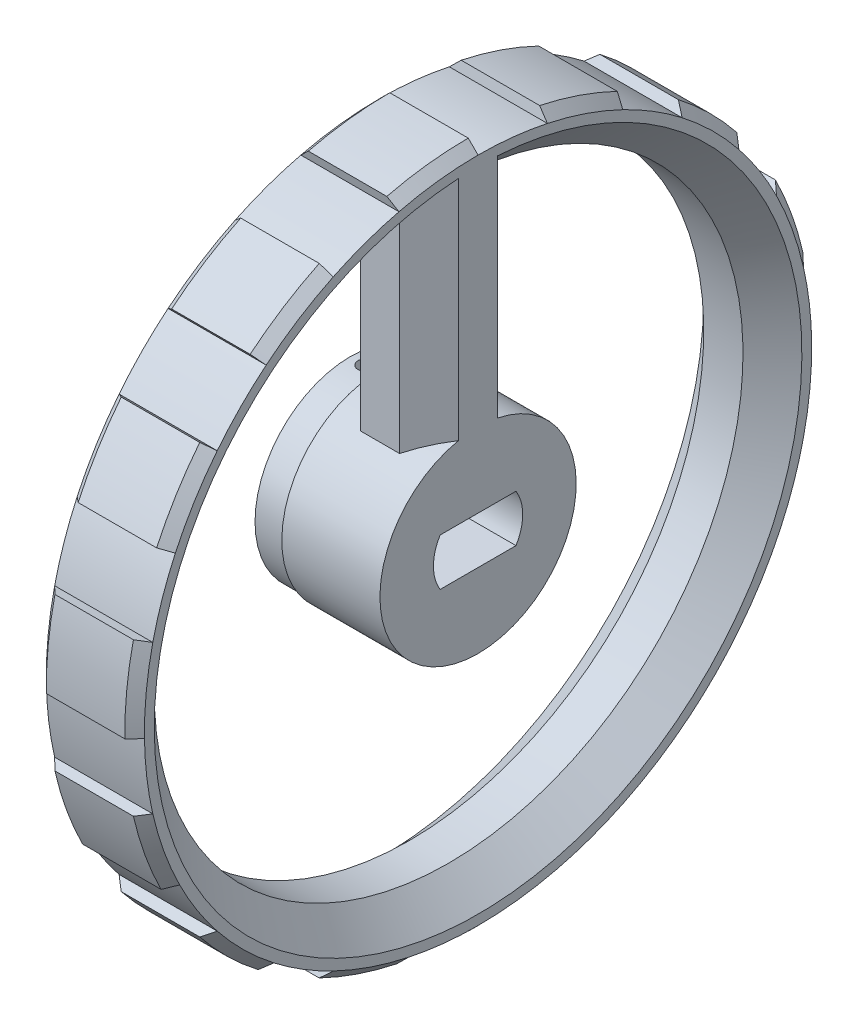
from build123d import *

# Parameters (mm, degrees)
SKETCH1_R               = 35
BOSS_EXTRUDE1_DEPTH     = 10
CHAMFER1_SIZE           = 1
CUT_EXTRUDE1_DEPTH      = 11
SKETCH3_R               = 1.5
CUT_EXTRUDE2_DEPTH      = 11
CUT_EXTRUDE3_DEPTH      = 10
SKETCH5_R               = 9.729015648
BOSS_EXTRUDE2_DEPTH     = 3
SKETCH6_R               = 0.75
CUT_EXTRUDE4_DEPTH      = 36
CUT_EXTRUDE4_DEPTH_BACK = 36
CHAMFER2_SIZE           = 3


with BuildPart() as part:
    # Sketch1 → Boss-Extrude1 (new body)
    with BuildSketch(Plane(origin=(0, 0, 0), x_dir=(0, 0, -1), z_dir=(1, 0, 0))):
        Circle(SKETCH1_R)
        with BuildLine():
            Line((-5, 29.580398915), (-5, 8.660254038))
            ThreePointArc((-5, 8.660254038), (0, -10), (5, 8.660254038))
            Line((5, 8.660254038), (5, 29.580398915))
            ThreePointArc((5, 29.580398915), (0, -30), (-5, 29.580398915))
        make_face(mode=Mode.SUBTRACT)
    extrude(amount=BOSS_EXTRUDE1_DEPTH)

    # Chamfer1
    chamfer1_edges = [part.edges().sort_by_distance(p)[0] for p in [
        (0, 0, 35),
        (10, 0, 35),
    ]]
    chamfer(chamfer1_edges, length=CHAMFER1_SIZE)

    # Sketch2 → Cut-Extrude1 (cut, through all)
    with BuildSketch(Plane(origin=(10, 0, 0), x_dir=(0, 0, -1), z_dir=(1, 0, 0))):
        with BuildLine():
            Line((0, 35), (0, 34))
            ThreePointArc((0, 34), (3.553967751, 33.813744443), (7.068997488, 33.257018425))
            Line((7.068997488, 33.257018425), (7.276909179, 34.235166026))
            ThreePointArc((7.276909179, 34.235166026), (3.658496214, 34.808266338), (0, 35))
        make_face()
        with BuildLine():
            Line((15.185930869, 31.533910377), (14.75204713, 30.632941509))
            ThreePointArc((14.75204713, 30.632941509), (17.873248174, 28.923122233), (20.79862617, 26.896415178))
            Line((20.79862617, 26.896415178), (21.410350469, 27.687486213))
            ThreePointArc((21.410350469, 27.687486213), (18.398931943, 29.773802299), (15.185930869, 31.533910377))
        make_face()
        with BuildLine():
            Line((27.364101886, 21.822143065), (26.582270404, 21.198653263))
            ThreePointArc((26.582270404, 21.198653263), (28.652512594, 18.303920947), (30.408831861, 15.208647043))
            Line((30.408831861, 15.208647043), (31.303209268, 15.655960191))
            ThreePointArc((31.303209268, 15.655960191), (29.495233553, 18.842271563), (27.364101886, 21.822143065))
        make_face()
        with BuildLine():
            Line((34.122476926, 7.788232688), (33.147549014, 7.565711755))
            ThreePointArc((33.147549014, 7.565711755), (33.756795496, 4.059403634), (33.996195462, 0.508619839))
            Line((33.996195462, 0.508619839), (34.996083563, 0.523579246))
            ThreePointArc((34.996083563, 0.523579246), (34.749642422, 4.178797859), (34.122476926, 7.788232688))
        make_face()
        with BuildLine():
            Line((34.122476926, -7.788232688), (33.147549014, -7.565711755))
            ThreePointArc((33.147549014, -7.565711755), (32.175131049, -10.989128353), (30.850195615, -14.292145763))
            Line((30.850195615, -14.292145763), (31.75755431, -14.712502991))
            ThreePointArc((31.75755431, -14.712502991), (33.121458433, -11.312338011), (34.122476926, -7.788232688))
        make_face()
        with BuildLine():
            Line((27.364101886, -21.822143065), (26.582270404, -21.198653263))
            ThreePointArc((26.582270404, -21.198653263), (24.220787296, -23.861128698), (21.593936175, -26.262176614))
            Line((21.593936175, -26.262176614), (22.229051944, -27.034593573))
            ThreePointArc((22.229051944, -27.034593573), (24.933163393, -24.562926601), (27.364101886, -21.822143065))
        make_face()
        with BuildLine():
            Line((15.185930869, -31.533910377), (14.75204713, -30.632941509))
            ThreePointArc((14.75204713, -30.632941509), (11.469219571, -32.007139866), (8.060732842, -33.030661302))
            Line((8.060732842, -33.030661302), (8.29781322, -34.00215134))
            ThreePointArc((8.29781322, -34.00215134), (11.806549558, -32.948526333), (15.185930869, -31.533910377))
        make_face()
        with BuildLine():
            Line((0, -35), (0, -34))
            ThreePointArc((0, -34), (-3.553967751, -33.813744443), (-7.068997488, -33.257018425))
            Line((-7.068997488, -33.257018425), (-7.276909179, -34.235166026))
            ThreePointArc((-7.276909179, -34.235166026), (-3.658496214, -34.808266338), (0, -35))
        make_face()
        with BuildLine():
            Line((-15.185930869, -31.533910377), (-14.75204713, -30.632941509))
            ThreePointArc((-14.75204713, -30.632941509), (-17.873248174, -28.923122233), (-20.79862617, -26.896415178))
            Line((-20.79862617, -26.896415178), (-21.410350469, -27.687486213))
            ThreePointArc((-21.410350469, -27.687486213), (-18.398931943, -29.773802299), (-15.185930869, -31.533910377))
        make_face()
        with BuildLine():
            Line((-27.364101886, -21.822143065), (-26.582270404, -21.198653263))
            ThreePointArc((-26.582270404, -21.198653263), (-28.652512594, -18.303920947), (-30.408831861, -15.208647043))
            Line((-30.408831861, -15.208647043), (-31.303209268, -15.655960191))
            ThreePointArc((-31.303209268, -15.655960191), (-29.495233553, -18.842271563), (-27.364101886, -21.822143065))
        make_face()
        with BuildLine():
            Line((-34.122476926, -7.788232688), (-33.147549014, -7.565711755))
            ThreePointArc((-33.147549014, -7.565711755), (-33.756795496, -4.059403634), (-33.996195462, -0.508619839))
            Line((-33.996195462, -0.508619839), (-34.996083563, -0.523579246))
            ThreePointArc((-34.996083563, -0.523579246), (-34.749642422, -4.178797859), (-34.122476926, -7.788232688))
        make_face()
        with BuildLine():
            Line((-34.122476926, 7.788232688), (-33.147549014, 7.565711755))
            ThreePointArc((-33.147549014, 7.565711755), (-32.175131049, 10.989128353), (-30.850195615, 14.292145763))
            Line((-30.850195615, 14.292145763), (-31.75755431, 14.712502991))
            ThreePointArc((-31.75755431, 14.712502991), (-33.121458433, 11.312338011), (-34.122476926, 7.788232688))
        make_face()
        with BuildLine():
            Line((-27.364101886, 21.822143065), (-26.582270404, 21.198653263))
            ThreePointArc((-26.582270404, 21.198653263), (-24.220787296, 23.861128698), (-21.593936175, 26.262176614))
            Line((-21.593936175, 26.262176614), (-22.229051944, 27.034593573))
            ThreePointArc((-22.229051944, 27.034593573), (-24.933163393, 24.562926601), (-27.364101886, 21.822143065))
        make_face()
        with BuildLine():
            Line((-15.185930869, 31.533910377), (-14.75204713, 30.632941509))
            ThreePointArc((-14.75204713, 30.632941509), (-11.469219571, 32.007139866), (-8.060732842, 33.030661302))
            Line((-8.060732842, 33.030661302), (-8.29781322, 34.00215134))
            ThreePointArc((-8.29781322, 34.00215134), (-11.806549558, 32.948526333), (-15.185930869, 31.533910377))
        make_face()
    extrude(amount=-CUT_EXTRUDE1_DEPTH, mode=Mode.SUBTRACT)

    # Sketch3 → Cut-Extrude2 (cut, through all)
    with BuildSketch(Plane.ZY):
        Circle(SKETCH3_R)
    extrude(amount=-CUT_EXTRUDE2_DEPTH, mode=Mode.SUBTRACT)

    # Sketch4 → Cut-Extrude3 (cut)
    with BuildSketch(Plane.ZY):
        with BuildLine():
            Line((-3.865553001, -2.4), (3.865553001, -2.4))
            ThreePointArc((3.865553001, -2.4), (4.55, 0), (3.865553001, 2.4))
            Line((3.865553001, 2.4), (-3.865553001, 2.4))
            ThreePointArc((-3.865553001, 2.4), (-4.55, 0), (-3.865553001, -2.4))
        make_face()
    extrude(amount=-CUT_EXTRUDE3_DEPTH, mode=Mode.SUBTRACT)

    # Sketch5 → Boss-Extrude2 (add)
    with BuildSketch(Plane.ZY):
        Circle(SKETCH5_R)
        with BuildLine():
            Line((-3.865553001, 2.4), (3.865553001, 2.4))
            ThreePointArc((3.865553001, 2.4), (4.568220616, 0), (3.865553001, -2.4))
            Line((3.865553001, -2.4), (-3.865553001, -2.4))
            ThreePointArc((-3.865553001, -2.4), (-4.568220616, 0), (-3.865553001, 2.4))
        make_face(mode=Mode.SUBTRACT)
    extrude(amount=BOSS_EXTRUDE2_DEPTH)

    # Sketch6 → Cut-Extrude4 (cut, two sides)
    with BuildSketch(Plane(origin=(0, 0, 0), x_dir=(1, 0, 0), z_dir=(0, 1, 0))) as cut_extrude4_sk:
        with Locations((-1.5, 0)):
            Circle(SKETCH6_R)
    extrude(amount=CUT_EXTRUDE4_DEPTH, mode=Mode.SUBTRACT)
    extrude(cut_extrude4_sk.sketch, amount=-CUT_EXTRUDE4_DEPTH_BACK, mode=Mode.SUBTRACT)

    # Chamfer2
    chamfer2_edges = [part.edges().sort_by_distance(p)[0] for p in [
        (10, 19.120326477, 5),
        (0, -30, 0),
        (0, 19.120326477, -5),
        (0, 19.120326477, 5),
        (10, -30, 0),
        (10, 19.120326477, -5),
    ]]
    chamfer(chamfer2_edges, length=CHAMFER2_SIZE)


solid = part.part
